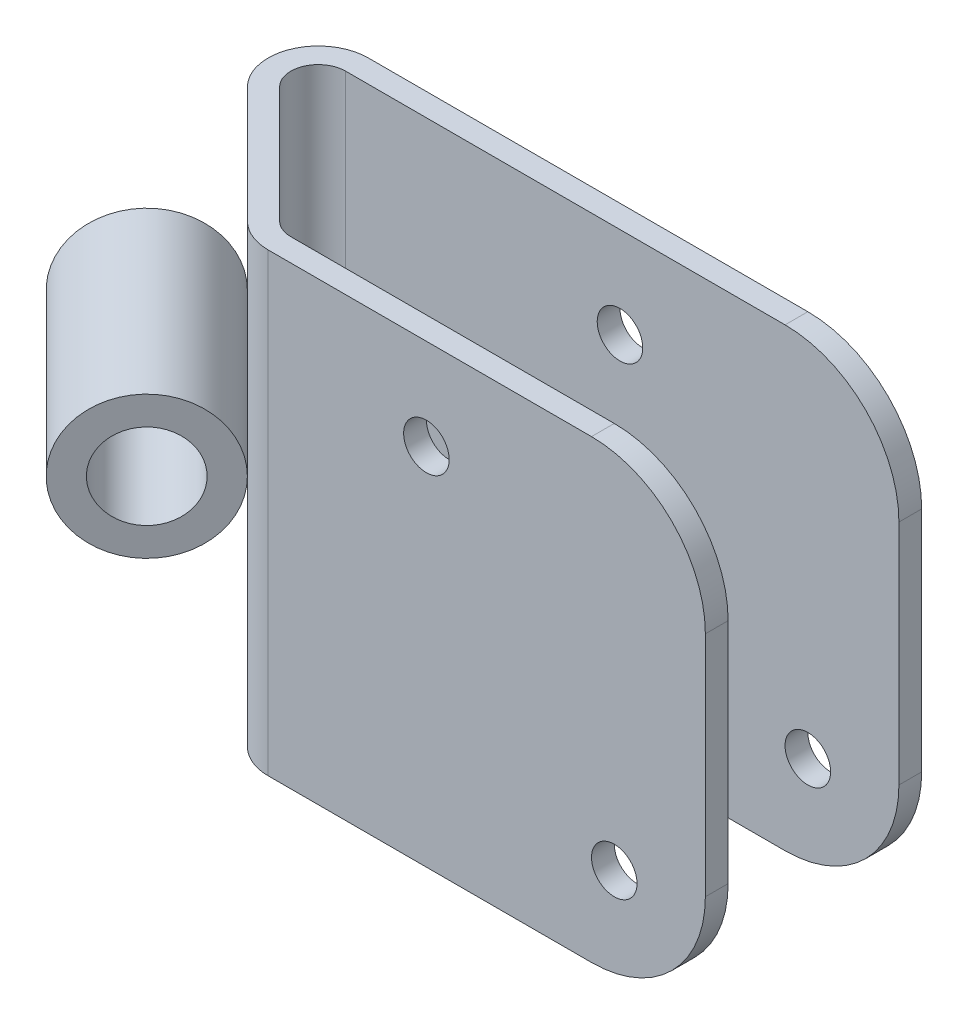
from build123d import *

# Parameters (mm, degrees)
EXTRUDE_THIN1_DEPTH = 25.4
SKETCH2_R           = 7.9375
SKETCH2_R_2         = 4.7625
BOSS_EXTRUDE2_DEPTH = 25.4
FILLET1_R           = 12.7
SKETCH4_R           = 2.54
CUT_EXTRUDE1_DEPTH  = 33.977781169


with BuildPart() as part:
    # Sketch1 → Extrude-Thin1 (new body, symmetric)
    with BuildSketch(Plane(origin=(0, 0, 0), x_dir=(1, 0, 0), z_dir=(0, 1, 0))):
        with BuildLine():
            Line((61.722, -24.13), (12.954, -24.13))
            ThreePointArc((12.954, -24.13), (10.81556498, -23.704638828), (9.002687307, -22.493312693))
            Line((9.002687307, -22.493312693), (-3.951312693, -9.539312693))
            ThreePointArc((-3.951312693, -9.539312693), (-5.162638828, -3.44956498), (0, 0))
            Line((0, 0), (61.722, 0))
            Line((61.722, 0), (61.722, -2.54))
            Line((61.722, -2.54), (0, -2.54))
            ThreePointArc((0, -2.54), (-2.815984815, -4.421580898), (-2.155261469, -7.743261469))
            Line((-2.155261469, -7.743261469), (10.798738531, -20.697261469))
            ThreePointArc((10.798738531, -20.697261469), (11.787580898, -21.357984815), (12.954, -21.59))
            Line((12.954, -21.59), (61.722, -21.59))
            Line((61.722, -21.59), (61.722, -24.13))
        make_face()
    extrude(amount=EXTRUDE_THIN1_DEPTH, both=True)

    # Fillet1
    fillet1_edges = [part.edges().sort_by_distance(p)[0] for p in [
        (61.722, -25.4, 1.27),
        (61.722, -25.4, 22.86),
        (61.722, 25.4, 1.27),
        (61.722, 25.4, 22.86),
    ]]
    fillet(fillet1_edges, radius=FILLET1_R)

    # Sketch4 → Cut-Extrude1 (cut, through all)
    with BuildSketch(Plane(origin=(0, 0, 0), x_dir=(-1, 0, 0), z_dir=(0, 0, -1))):
        with Locations((-51.562, -15.24)):
            Circle(SKETCH4_R)
        with Locations((-30.607, 15.24)):
            Circle(SKETCH4_R)
    extrude(amount=-CUT_EXTRUDE1_DEPTH, mode=Mode.SUBTRACT)


with BuildPart() as body_2:
    # Sketch2 → Boss-Extrude2 (new body)
    with BuildSketch(Plane(origin=(-9.698676611, 25.4, 3.791948776), x_dir=(0.707106781, 0, -0.707106781), z_dir=(0.707106781, 0, 0.707106781))):
        with Locations((-7.9375, -25.4)):
            Circle(SKETCH2_R)
        with Locations((-7.9375, -25.4)):
            Circle(SKETCH2_R_2, mode=Mode.SUBTRACT)
    extrude(amount=BOSS_EXTRUDE2_DEPTH)


solid = Compound([part.part, body_2.part])
